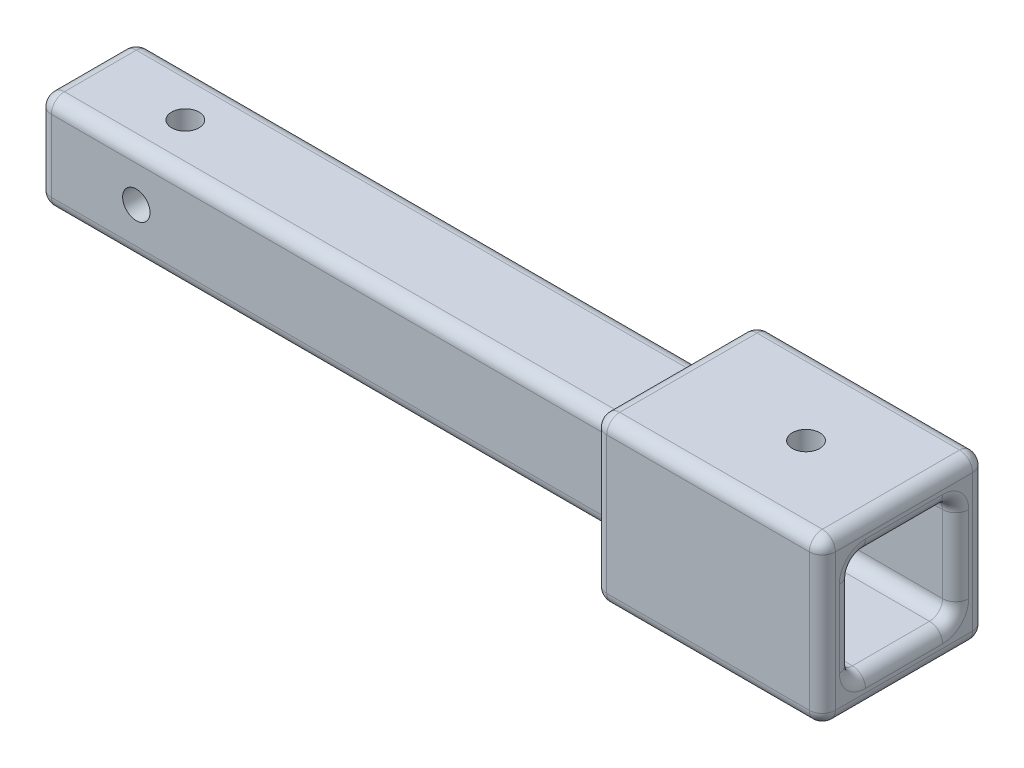
from build123d import *

# Parameters (mm, degrees)
BOSS_EXTRUDE1_DEPTH      = 7.5
BOSS_EXTRUDE1_DEPTH_BACK = 7.5
SKETCH1_W                = 90
SKETCH1_H                = 15
BOSS_EXTRUDE2_DEPTH      = 12.5
BOSS_EXTRUDE2_DEPTH_BACK = 12.5
SKETCH3_R                = 2.1
CUT_EXTRUDE1_DEPTH       = 128.205542332
SKETCH5_R                = 2.1
CUT_EXTRUDE3_DEPTH       = 130.034879006
SKETCH6_W                = 15.8
SKETCH6_H                = 15.8
CUT_EXTRUDE4_DEPTH       = 32
SKETCH8_R                = 2.1
CUT_EXTRUDE5_DEPTH       = 129.16005618
FILLET1_R                = 2


with BuildPart() as part:
    # Sketch1 → Boss-Extrude1 (new, two sides: drawn at the far end of the back side and taken through both)
    with BuildSketch(Plane(origin=(0, 0, 0), x_dir=(1, 0, 0), z_dir=(0, 1, 0)).offset(-BOSS_EXTRUDE1_DEPTH_BACK)):
        with Locations((45, -7.5)):
            Rectangle(SKETCH1_W, SKETCH1_H)
    extrude(amount=BOSS_EXTRUDE1_DEPTH + BOSS_EXTRUDE1_DEPTH_BACK)

    # Sketch1_3 → Boss-Extrude2 (add, two sides: drawn at the far end of the back side and taken through both)
    with BuildSketch(Plane(origin=(0, 0, 0), x_dir=(1, 0, 0), z_dir=(0, 1, 0)).offset(-BOSS_EXTRUDE2_DEPTH_BACK)):
        Polygon((90, 0), (90, -15), (90, -20), (125, -20), (125, 5), (90, 5), align=None)
    extrude(amount=BOSS_EXTRUDE2_DEPTH + BOSS_EXTRUDE2_DEPTH_BACK)

    # Sketch3 → Cut-Extrude1 (cut, through all)
    with BuildSketch(Plane.XY.offset(15)):
        with Locations((15, 0)):
            Circle(SKETCH3_R)
    extrude(amount=-CUT_EXTRUDE1_DEPTH, mode=Mode.SUBTRACT)

    # Sketch5 → Cut-Extrude3 (cut, through all)
    with BuildSketch(Plane(origin=(0, 12.5, 0), x_dir=(1, 0, 0), z_dir=(0, 1, 0))):
        with Locations((110, -7.5)):
            Circle(SKETCH5_R)
    extrude(amount=-CUT_EXTRUDE3_DEPTH, mode=Mode.SUBTRACT)

    # Sketch6 → Cut-Extrude4 (cut)
    with BuildSketch(Plane(origin=(125, 0, 0), x_dir=(0, 0, -1), z_dir=(1, 0, 0))):
        with Locations((-7.5, 0)):
            Rectangle(SKETCH6_W, SKETCH6_H)
    extrude(amount=-CUT_EXTRUDE4_DEPTH, mode=Mode.SUBTRACT)

    # Sketch8 → Cut-Extrude5 (cut, through all)
    with BuildSketch(Plane.XZ.offset(7.5)):
        with Locations((15, 7.5)):
            Circle(SKETCH8_R)
    extrude(amount=-CUT_EXTRUDE5_DEPTH, mode=Mode.SUBTRACT)

    # Fillet1
    fillet1_edges = [part.edges().sort_by_distance(p)[0] for p in [
        (125, -12.5, 7.5),
        (125, 0, 20),
        (125, 12.5, 7.5),
        (125, 0, -5),
        (93, -7.9, 7.5),
        (109, 7.9, 15.4),
        (93, 7.9, 7.5),
        (93, 0, -0.4),
        (93, 0, 15.4),
        (109, -7.9, 15.4),
        (109, -7.9, -0.4),
        (109, 7.9, -0.4),
        (107.5, 12.5, -5),
        (90, 12.5, 7.5),
        (107.5, 12.5, 20),
        (107.5, -12.5, 20),
        (90, -12.5, 7.5),
        (107.5, -12.5, -5),
        (90, 0, -5),
        (90, 0, 0),
        (90, -7.5, 7.5),
        (90, 0, 15),
        (90, 7.5, 7.5),
        (0, 0, 0),
        (0, 0, 15),
        (0, -7.5, 7.5),
        (0, 7.5, 7.5),
        (45, -7.5, 0),
        (45, -7.5, 15),
        (45, 7.5, 15),
        (45, 7.5, 0),
        (125, -7.9, 7.5),
        (125, 0, 15.4),
        (125, 7.9, 7.5),
        (125, 0, -0.4),
        (90, 0, 20),
    ]]
    fillet(fillet1_edges, radius=FILLET1_R)


solid = part.part
